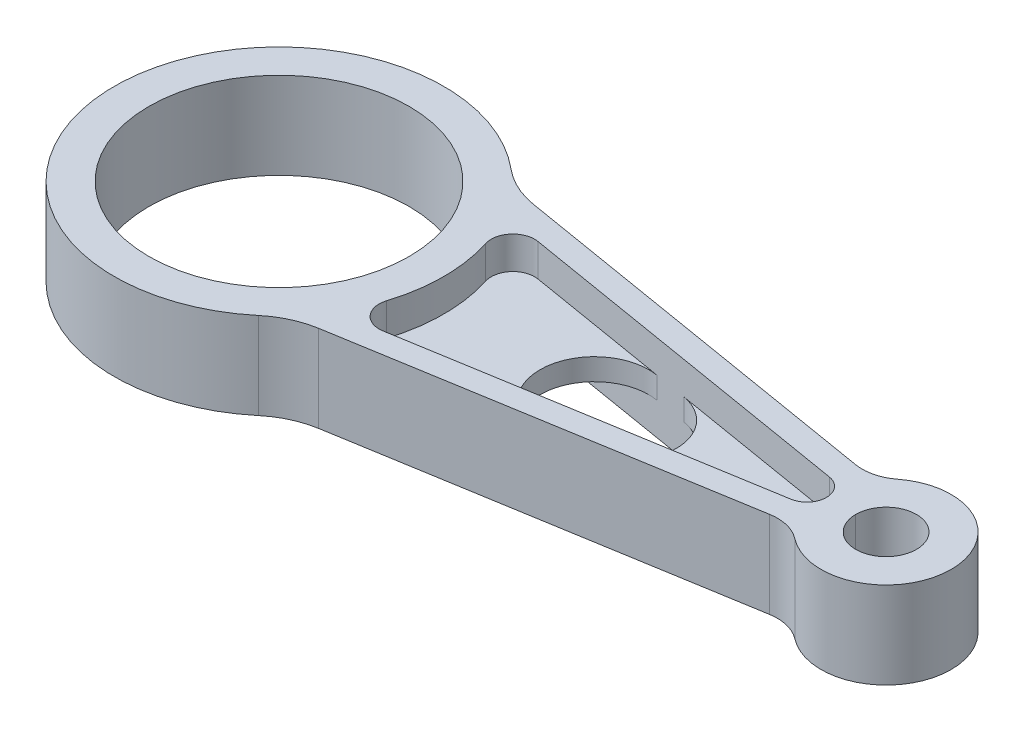
from build123d import *

# Parameters (mm, degrees)
SKETCH1_R           = 30
SKETCH1_R_2         = 7
BOSS_EXTRUDE1_DEPTH = 10
FILLET1_R           = 10
FILLET2_R           = 20
CUT_EXTRUDE4_DEPTH  = 21
BOSS_EXTRUDE2_DEPTH = 2.5
CUT_EXTRUDE3_DEPTH  = 21


with BuildPart() as part:
    # Sketch1 → Boss-Extrude1 (new body, symmetric)
    with BuildSketch(Plane(origin=(0, 0, 0), x_dir=(1, 0, 0), z_dir=(0, 1, 0))):
        with BuildLine():
            Line((27.935473676, 25.760615491), (128.063755469, 9.084385863))
            ThreePointArc((128.063755469, 9.084385863), (155, 0), (128.063755469, -9.084385863))
            Line((128.063755469, -9.084385863), (27.935473676, -25.760615491))
            ThreePointArc((27.935473676, -25.760615491), (-38, 0), (27.935473676, 25.760615491))
        make_face()
        Circle(SKETCH1_R, mode=Mode.SUBTRACT)
        with Locations((140, 0)):
            Circle(SKETCH1_R_2, mode=Mode.SUBTRACT)
    extrude(amount=BOSS_EXTRUDE1_DEPTH, both=True)

    # Fillet1
    fillet1_edges = [part.edges().sort_by_distance(p)[0] for p in [
        (128.063755469, 0, -9.084385863),
        (128.063755469, 0, 9.084385863),
    ]]
    fillet(fillet1_edges, radius=FILLET1_R)

    # Fillet2
    fillet2_edges = [part.edges().sort_by_distance(p)[0] for p in [
        (27.935473676, 0, -25.760615491),
        (27.935473676, 0, 25.760615491),
    ]]
    fillet(fillet2_edges, radius=FILLET2_R)

    # Sketch14 → Cut-Extrude4 (cut, through all)
    with BuildSketch(Plane(origin=(0, 10, 0), x_dir=(1, 0, 0), z_dir=(0, 1, 0))):
        with BuildLine():
            Line((41.828554558, 17.870982725), (122.478416149, 4.438857582))
            ThreePointArc((122.478416149, 4.438857582), (126.239130435, 0), (122.478416149, -4.438857582))
            Line((122.478416149, -4.438857582), (41.828554558, -17.870982725))
            ThreePointArc((41.828554558, -17.870982725), (37.231968897, -16.217361812), (36.238855523, -11.43439331))
            ThreePointArc((36.238855523, -11.43439331), (38, 0), (36.238855523, 11.43439331))
            ThreePointArc((36.238855523, 11.43439331), (37.231968897, 16.217361812), (41.828554558, 17.870982725))
        make_face()
    extrude(amount=-CUT_EXTRUDE4_DEPTH, mode=Mode.SUBTRACT)

    # Sketch11 → Boss-Extrude2 (add, symmetric)
    with BuildSketch(Plane(origin=(0, 0, 0), x_dir=(1, 0, 0), z_dir=(0, 1, 0))):
        with BuildLine():
            Line((41.828554558, 17.870982725), (122.478416149, 4.438857582))
            ThreePointArc((122.478416149, 4.438857582), (126.239130435, 0), (122.478416149, -4.438857582))
            Line((122.478416149, -4.438857582), (41.828554558, -17.870982725))
            ThreePointArc((41.828554558, -17.870982725), (37.231968897, -16.217361812), (36.238855523, -11.43439331))
            ThreePointArc((36.238855523, -11.43439331), (38, 0), (36.238855523, 11.43439331))
            ThreePointArc((36.238855523, 11.43439331), (37.231968897, 16.217361812), (41.828554558, 17.870982725))
        make_face()
    extrude(amount=BOSS_EXTRUDE2_DEPTH, both=True)

    # Sketch2 → Cut-Extrude3 (cut, through all)
    with BuildSketch(Plane(origin=(0, 10, 0), x_dir=(1, 0, 0), z_dir=(0, 1, 0))):
        with BuildLine():
            Line((74.800916149, 12.37948059), (82.190906374, 11.148687733))
            ThreePointArc((82.190906374, 11.148687733), (91.636361303, 0), (82.190906374, -11.148687733))
            Line((82.190906374, -11.148687733), (74.800916149, -12.37948059))
            ThreePointArc((74.800916149, -12.37948059), (60.189130435, 0), (74.800916149, 12.37948059))
        make_face()
    extrude(amount=-CUT_EXTRUDE3_DEPTH, mode=Mode.SUBTRACT)


solid = part.part
